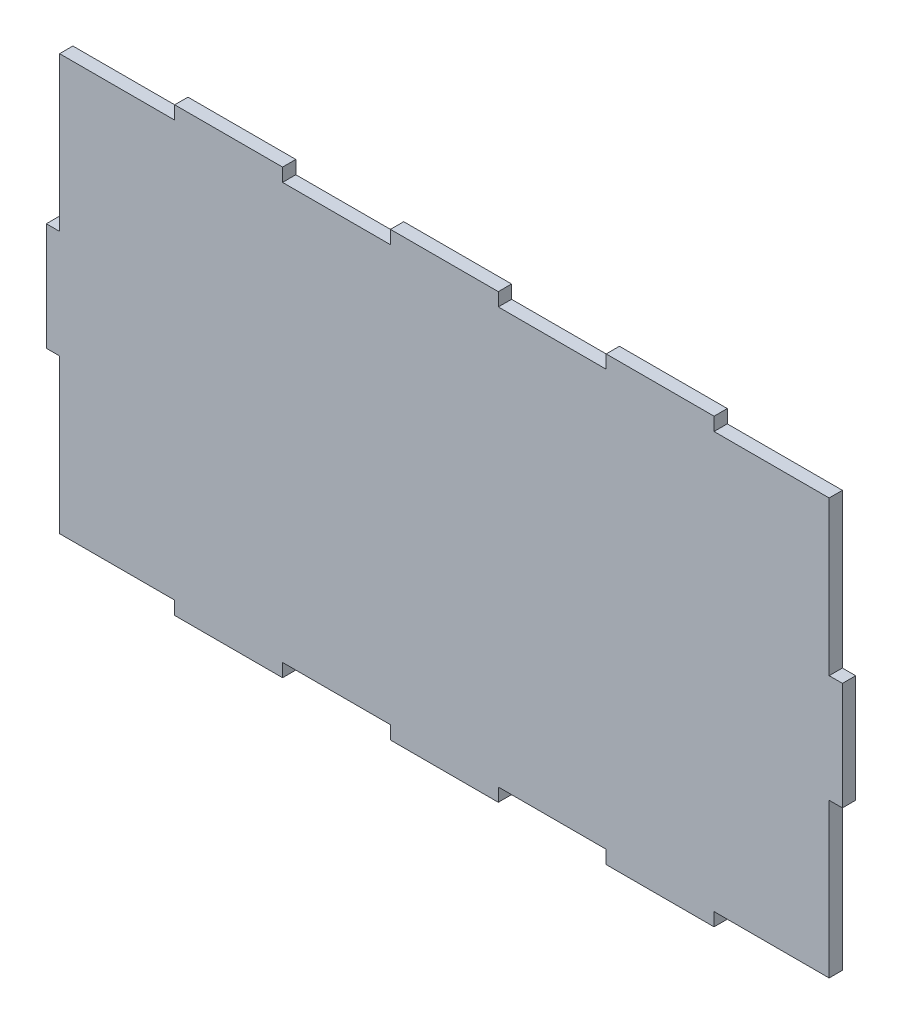
from build123d import *

# Parameters (mm, degrees)
SALIENTE_EXTRUIR1_DEPTH = 3


with BuildPart() as part:
    # Model → Saliente-Extruir1 (new body)
    with BuildSketch(Plane.XY):
        Polygon((289, 97), (289, 62.195), (286, 62.195), (286, 37.805), (289, 37.805), (289, 13.415), (289, 3), (315.025, 3), (315.025, 0), (339.415, 0), (339.415, 3), (363.805, 3), (363.805, 0), (388.195, 0), (388.195, 3), (412.585, 3), (412.585, 0), (436.975, 0), (436.975, 3), (461.365, 3), (463, 3), (463, 37.805), (466, 37.805), (466, 62.195), (463, 62.195), (463, 86.585), (463, 97), (436.975, 97), (436.975, 100), (412.585, 100), (412.585, 97), (388.195, 97), (388.195, 100), (363.805, 100), (363.805, 97), (339.415, 97), (339.415, 100), (315.025, 100), (315.025, 97), (290.635, 97), align=None)
    extrude(amount=SALIENTE_EXTRUIR1_DEPTH)


solid = part.part
